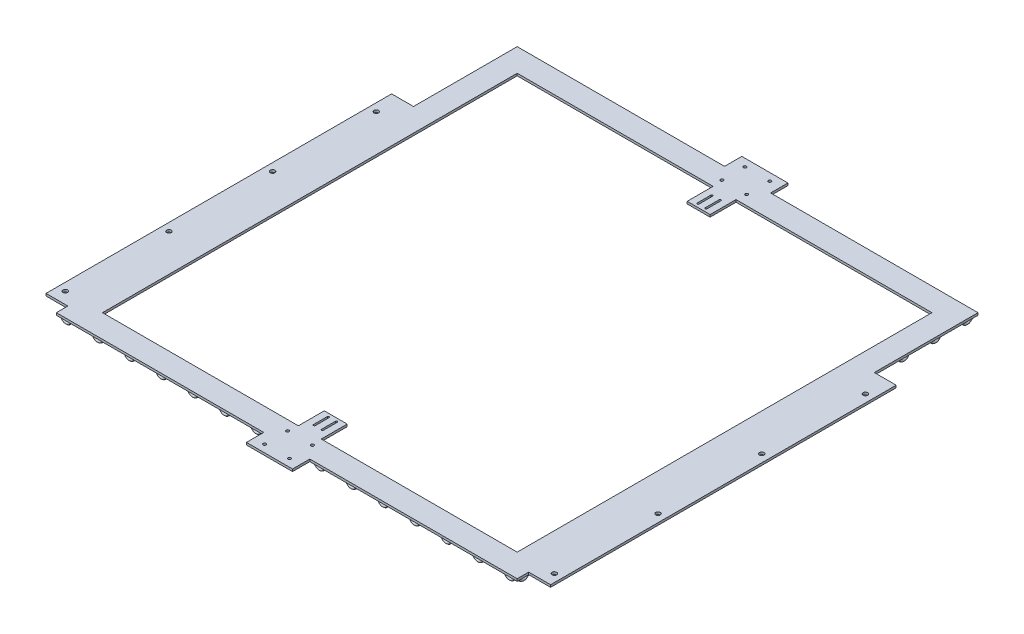
from build123d import *

# Parameters (mm, degrees)
SKETCH_1_R                = 2.5
SKETCH_1_W                = 38
SKETCH_1_H                = 600
EXTRUDE_1_DEPTH           = 4
SKETCH_19_R               = 4
CUT_EXTRUDE_2_DEPTH       = 20
SKETCH_14_R               = 2
SKETCH_18_R               = 2
PATTERN_LINEAR_3_COUNT    = 15
PATTERN_LINEAR_3_PITCH    = 55
MIRROR_1_COPY_1_SKETCH_R  = 2
MIRROR_1_COPY_2_SKETCH_R  = 2
MIRROR_1_COPY_3_SKETCH_R  = 2
MIRROR_1_COPY_4_SKETCH_R  = 2
MIRROR_1_COPY_5_SKETCH_R  = 2
MIRROR_1_COPY_6_SKETCH_R  = 2
MIRROR_1_COPY_7_SKETCH_R  = 2
MIRROR_1_COPY_8_SKETCH_R  = 2
MIRROR_1_COPY_9_SKETCH_R  = 2
MIRROR_1_COPY_10_SKETCH_R = 2
MIRROR_1_COPY_11_SKETCH_R = 2
MIRROR_1_COPY_12_SKETCH_R = 2
MIRROR_1_COPY_13_SKETCH_R = 2
MIRROR_1_COPY_14_SKETCH_R = 2
PATTERN_LINEAR_4_COUNT    = 15
PATTERN_LINEAR_4_PITCH    = 55
MIRROR_2_COPY_1_SKETCH_R  = 2
MIRROR_2_COPY_2_SKETCH_R  = 2
MIRROR_2_COPY_3_SKETCH_R  = 2
MIRROR_2_COPY_4_SKETCH_R  = 2
MIRROR_2_COPY_5_SKETCH_R  = 2
MIRROR_2_COPY_6_SKETCH_R  = 2
MIRROR_2_COPY_7_SKETCH_R  = 2
MIRROR_2_COPY_8_SKETCH_R  = 2
MIRROR_2_COPY_9_SKETCH_R  = 2
MIRROR_2_COPY_10_SKETCH_R = 2
MIRROR_2_COPY_11_SKETCH_R = 2
MIRROR_2_COPY_12_SKETCH_R = 2
MIRROR_2_COPY_13_SKETCH_R = 2


with BuildPart() as part:
    # 草图1 → 凸台-拉伸1 (new body)
    with BuildSketch(Plane(origin=(0, 0, 0), x_dir=(1, 0, 0), z_dir=(0, 1, 0))):
        Polygon((-400, 20), (-400, 0), (-40, 0), (-40, -30), (40, -30), (40, 0), (400, 0), (400, 20), (400, 620), (400, 800), (40, 800), (40, 830), (-40, 830), (-40, 800), (-400, 800), (-400, 620), align=None)
        with Locations((-21.5, -16.998099011)):
            Circle(SKETCH_1_R, mode=Mode.SUBTRACT)
        with Locations((-21.5, 23.001900989)):
            Circle(SKETCH_1_R, mode=Mode.SUBTRACT)
        with BuildLine():
            ThreePointArc((-8.65, 79.001900989), (-7.05, 80.601900989), (-5.45, 79.001900989))
            Line((-5.45, 79.001900989), (-5.45, 55.001900989))
            ThreePointArc((-5.45, 55.001900989), (-7.05, 53.401900989), (-8.65, 55.001900989))
            Line((-8.65, 55.001900989), (-8.65, 79.001900989))
        make_face(mode=Mode.SUBTRACT)
        Polygon((-40, 40), (-360, 40), (-360, 760), (-40, 760), (-19.900430503, 760), (-19.900430503, 715), (19.900430503, 715), (19.900430503, 760), (40, 760), (360, 760), (360, 40), (40, 40), (19.900430503, 40), (19.900430503, 85), (-19.900430503, 85), (-19.900430503, 40), align=None, mode=Mode.SUBTRACT)
        with Locations((21.5, -16.998099011)):
            Circle(SKETCH_1_R, mode=Mode.SUBTRACT)
        with Locations((21.5, 23.001900989)):
            Circle(SKETCH_1_R, mode=Mode.SUBTRACT)
        with BuildLine():
            ThreePointArc((8.65, 55.001900989), (7.05, 53.401900989), (5.45, 55.001900989))
            Line((5.45, 55.001900989), (5.45, 79.001900989))
            ThreePointArc((5.45, 79.001900989), (7.05, 80.601900989), (8.65, 79.001900989))
            Line((8.65, 79.001900989), (8.65, 55.001900989))
        make_face(mode=Mode.SUBTRACT)
        with BuildLine():
            ThreePointArc((-8.65, 744.998099011), (-7.05, 746.598099011), (-5.45, 744.998099011))
            Line((-5.45, 744.998099011), (-5.45, 720.998099011))
            ThreePointArc((-5.45, 720.998099011), (-7.05, 719.398099011), (-8.65, 720.998099011))
            Line((-8.65, 720.998099011), (-8.65, 744.998099011))
        make_face(mode=Mode.SUBTRACT)
        with Locations((-21.5, 776.998099011)):
            Circle(SKETCH_1_R, mode=Mode.SUBTRACT)
        with Locations((-21.5, 816.998099011)):
            Circle(SKETCH_1_R, mode=Mode.SUBTRACT)
        with BuildLine():
            ThreePointArc((8.65, 720.998099011), (7.05, 719.398099011), (5.45, 720.998099011))
            Line((5.45, 720.998099011), (5.45, 744.998099011))
            ThreePointArc((5.45, 744.998099011), (7.05, 746.598099011), (8.65, 744.998099011))
            Line((8.65, 744.998099011), (8.65, 720.998099011))
        make_face(mode=Mode.SUBTRACT)
        with Locations((21.5, 776.998099011)):
            Circle(SKETCH_1_R, mode=Mode.SUBTRACT)
        with Locations((21.5, 816.998099011)):
            Circle(SKETCH_1_R, mode=Mode.SUBTRACT)
        with Locations((419, 320)):
            Rectangle(SKETCH_1_W, SKETCH_1_H)
        with Locations((-419, 320)):
            Rectangle(SKETCH_1_W, SKETCH_1_H)
    extrude(amount=EXTRUDE_1_DEPTH)

    # 草图19 → 切除-拉伸2 (cut, symmetric)
    with BuildSketch(Plane(origin=(0, 0, 0), x_dir=(1, 0, 0), z_dir=(0, 1, 0))):
        with Locations((-424.498179324, 220)):
            Circle(SKETCH_19_R)
        with Locations((-424.498179324, 400)):
            Circle(SKETCH_19_R)
        with Locations((-424.498179324, 580)):
            Circle(SKETCH_19_R)
        with Locations((-424.498179324, 40)):
            Circle(SKETCH_19_R)
        with Locations((424.498179324, 40)):
            Circle(SKETCH_19_R)
        with Locations((424.498179324, 580)):
            Circle(SKETCH_19_R)
        with Locations((424.498179324, 400)):
            Circle(SKETCH_19_R)
        with Locations((424.498179324, 220)):
            Circle(SKETCH_19_R)
    extrude(amount=CUT_EXTRUDE_2_DEPTH, both=True, mode=Mode.SUBTRACT)

    # 扫描1: sweep along a path in 草图12
    with BuildLine(Plane.XY.offset(-6)) as sweep_1_path:
        ThreePointArc((-396, 0), (-388, -8), (-380, 0))
    # 草图14 → 扫描1 (sweep)
    with BuildSketch(Plane(origin=(0, 0, 0), x_dir=(1, 0, 0), z_dir=(0, 1, 0))):
        with Locations((-396, 6)):
            Circle(SKETCH_14_R)
    sweep_1 = sweep(path=sweep_1_path.line)

    # 扫描3: sweep along a path in 草图17
    with BuildLine(Plane.ZY.offset(394)) as sweep_3_path:
        ThreePointArc((-794.32, 0), (-786.32, -8), (-778.32, 0))
    # 草图18 → 扫描3 (sweep)
    with BuildSketch(Plane(origin=(0, 0, 0), x_dir=(1, 0, 0), z_dir=(0, 1, 0))):
        with Locations((-394, 794.32)):
            Circle(SKETCH_18_R)
    sweep_3 = sweep(path=sweep_3_path.line)

    # 阵列(线性)3: 扫描3 ×15
    with Locations(*[(0, 0, i * PATTERN_LINEAR_3_PITCH) for i in range(1, PATTERN_LINEAR_3_COUNT)]):
        add(sweep_3)

    # 镜向1: 扫描3 across plane
    add(sweep_3.mirror(Plane(origin=(0, 0, 0), x_dir=(0, 0, 1), z_dir=(1, 0, 0))))

    # 镜向1 copy 1: sweep along a path in 镜向1 copy 1 path
    with BuildLine(Plane(origin=(394, 0, 55), x_dir=(0, 0, 1), z_dir=(1, 0, 0))) as mirror_1_copy_1_path:
        ThreePointArc((-794.32, 0), (-786.32, 8), (-778.32, 0))
    # 镜向1 copy 1 sketch → 镜向1 copy 1 (sweep)
    with BuildSketch(Plane(origin=(0, 0, 55), x_dir=(-1, 0, 0), z_dir=(0, 1, 0))):
        with Locations((-394, -794.32)):
            Circle(MIRROR_1_COPY_1_SKETCH_R)
    sweep(path=mirror_1_copy_1_path.line)

    # 镜向1 copy 2: sweep along a path in 镜向1 copy 2 path
    with BuildLine(Plane(origin=(394, 0, 110), x_dir=(0, 0, 1), z_dir=(1, 0, 0))) as mirror_1_copy_2_path:
        ThreePointArc((-794.32, 0), (-786.32, 8), (-778.32, 0))
    # 镜向1 copy 2 sketch → 镜向1 copy 2 (sweep)
    with BuildSketch(Plane(origin=(0, 0, 110), x_dir=(-1, 0, 0), z_dir=(0, 1, 0))):
        with Locations((-394, -794.32)):
            Circle(MIRROR_1_COPY_2_SKETCH_R)
    sweep(path=mirror_1_copy_2_path.line)

    # 镜向1 copy 3: sweep along a path in 镜向1 copy 3 path
    with BuildLine(Plane(origin=(394, 0, 165), x_dir=(0, 0, 1), z_dir=(1, 0, 0))) as mirror_1_copy_3_path:
        ThreePointArc((-794.32, 0), (-786.32, 8), (-778.32, 0))
    # 镜向1 copy 3 sketch → 镜向1 copy 3 (sweep)
    with BuildSketch(Plane(origin=(0, 0, 165), x_dir=(-1, 0, 0), z_dir=(0, 1, 0))):
        with Locations((-394, -794.32)):
            Circle(MIRROR_1_COPY_3_SKETCH_R)
    sweep(path=mirror_1_copy_3_path.line)

    # 镜向1 copy 4: sweep along a path in 镜向1 copy 4 path
    with BuildLine(Plane(origin=(394, 0, 220), x_dir=(0, 0, 1), z_dir=(1, 0, 0))) as mirror_1_copy_4_path:
        ThreePointArc((-794.32, 0), (-786.32, 8), (-778.32, 0))
    # 镜向1 copy 4 sketch → 镜向1 copy 4 (sweep)
    with BuildSketch(Plane(origin=(0, 0, 220), x_dir=(-1, 0, 0), z_dir=(0, 1, 0))):
        with Locations((-394, -794.32)):
            Circle(MIRROR_1_COPY_4_SKETCH_R)
    sweep(path=mirror_1_copy_4_path.line)

    # 镜向1 copy 5: sweep along a path in 镜向1 copy 5 path
    with BuildLine(Plane(origin=(394, 0, 275), x_dir=(0, 0, 1), z_dir=(1, 0, 0))) as mirror_1_copy_5_path:
        ThreePointArc((-794.32, 0), (-786.32, 8), (-778.32, 0))
    # 镜向1 copy 5 sketch → 镜向1 copy 5 (sweep)
    with BuildSketch(Plane(origin=(0, 0, 275), x_dir=(-1, 0, 0), z_dir=(0, 1, 0))):
        with Locations((-394, -794.32)):
            Circle(MIRROR_1_COPY_5_SKETCH_R)
    sweep(path=mirror_1_copy_5_path.line)

    # 镜向1 copy 6: sweep along a path in 镜向1 copy 6 path
    with BuildLine(Plane(origin=(394, 0, 330), x_dir=(0, 0, 1), z_dir=(1, 0, 0))) as mirror_1_copy_6_path:
        ThreePointArc((-794.32, 0), (-786.32, 8), (-778.32, 0))
    # 镜向1 copy 6 sketch → 镜向1 copy 6 (sweep)
    with BuildSketch(Plane(origin=(0, 0, 330), x_dir=(-1, 0, 0), z_dir=(0, 1, 0))):
        with Locations((-394, -794.32)):
            Circle(MIRROR_1_COPY_6_SKETCH_R)
    sweep(path=mirror_1_copy_6_path.line)

    # 镜向1 copy 7: sweep along a path in 镜向1 copy 7 path
    with BuildLine(Plane(origin=(394, 0, 385), x_dir=(0, 0, 1), z_dir=(1, 0, 0))) as mirror_1_copy_7_path:
        ThreePointArc((-794.32, 0), (-786.32, 8), (-778.32, 0))
    # 镜向1 copy 7 sketch → 镜向1 copy 7 (sweep)
    with BuildSketch(Plane(origin=(0, 0, 385), x_dir=(-1, 0, 0), z_dir=(0, 1, 0))):
        with Locations((-394, -794.32)):
            Circle(MIRROR_1_COPY_7_SKETCH_R)
    sweep(path=mirror_1_copy_7_path.line)

    # 镜向1 copy 8: sweep along a path in 镜向1 copy 8 path
    with BuildLine(Plane(origin=(394, 0, 440), x_dir=(0, 0, 1), z_dir=(1, 0, 0))) as mirror_1_copy_8_path:
        ThreePointArc((-794.32, 0), (-786.32, 8), (-778.32, 0))
    # 镜向1 copy 8 sketch → 镜向1 copy 8 (sweep)
    with BuildSketch(Plane(origin=(0, 0, 440), x_dir=(-1, 0, 0), z_dir=(0, 1, 0))):
        with Locations((-394, -794.32)):
            Circle(MIRROR_1_COPY_8_SKETCH_R)
    sweep(path=mirror_1_copy_8_path.line)

    # 镜向1 copy 9: sweep along a path in 镜向1 copy 9 path
    with BuildLine(Plane(origin=(394, 0, 495), x_dir=(0, 0, 1), z_dir=(1, 0, 0))) as mirror_1_copy_9_path:
        ThreePointArc((-794.32, 0), (-786.32, 8), (-778.32, 0))
    # 镜向1 copy 9 sketch → 镜向1 copy 9 (sweep)
    with BuildSketch(Plane(origin=(0, 0, 495), x_dir=(-1, 0, 0), z_dir=(0, 1, 0))):
        with Locations((-394, -794.32)):
            Circle(MIRROR_1_COPY_9_SKETCH_R)
    sweep(path=mirror_1_copy_9_path.line)

    # 镜向1 copy 10: sweep along a path in 镜向1 copy 10 path
    with BuildLine(Plane(origin=(394, 0, 550), x_dir=(0, 0, 1), z_dir=(1, 0, 0))) as mirror_1_copy_10_path:
        ThreePointArc((-794.32, 0), (-786.32, 8), (-778.32, 0))
    # 镜向1 copy 10 sketch → 镜向1 copy 10 (sweep)
    with BuildSketch(Plane(origin=(0, 0, 550), x_dir=(-1, 0, 0), z_dir=(0, 1, 0))):
        with Locations((-394, -794.32)):
            Circle(MIRROR_1_COPY_10_SKETCH_R)
    sweep(path=mirror_1_copy_10_path.line)

    # 镜向1 copy 11: sweep along a path in 镜向1 copy 11 path
    with BuildLine(Plane(origin=(394, 0, 605), x_dir=(0, 0, 1), z_dir=(1, 0, 0))) as mirror_1_copy_11_path:
        ThreePointArc((-794.32, 0), (-786.32, 8), (-778.32, 0))
    # 镜向1 copy 11 sketch → 镜向1 copy 11 (sweep)
    with BuildSketch(Plane(origin=(0, 0, 605), x_dir=(-1, 0, 0), z_dir=(0, 1, 0))):
        with Locations((-394, -794.32)):
            Circle(MIRROR_1_COPY_11_SKETCH_R)
    sweep(path=mirror_1_copy_11_path.line)

    # 镜向1 copy 12: sweep along a path in 镜向1 copy 12 path
    with BuildLine(Plane(origin=(394, 0, 660), x_dir=(0, 0, 1), z_dir=(1, 0, 0))) as mirror_1_copy_12_path:
        ThreePointArc((-794.32, 0), (-786.32, 8), (-778.32, 0))
    # 镜向1 copy 12 sketch → 镜向1 copy 12 (sweep)
    with BuildSketch(Plane(origin=(0, 0, 660), x_dir=(-1, 0, 0), z_dir=(0, 1, 0))):
        with Locations((-394, -794.32)):
            Circle(MIRROR_1_COPY_12_SKETCH_R)
    sweep(path=mirror_1_copy_12_path.line)

    # 镜向1 copy 13: sweep along a path in 镜向1 copy 13 path
    with BuildLine(Plane(origin=(394, 0, 715), x_dir=(0, 0, 1), z_dir=(1, 0, 0))) as mirror_1_copy_13_path:
        ThreePointArc((-794.32, 0), (-786.32, 8), (-778.32, 0))
    # 镜向1 copy 13 sketch → 镜向1 copy 13 (sweep)
    with BuildSketch(Plane(origin=(0, 0, 715), x_dir=(-1, 0, 0), z_dir=(0, 1, 0))):
        with Locations((-394, -794.32)):
            Circle(MIRROR_1_COPY_13_SKETCH_R)
    sweep(path=mirror_1_copy_13_path.line)

    # 镜向1 copy 14: sweep along a path in 镜向1 copy 14 path
    with BuildLine(Plane(origin=(394, 0, 770), x_dir=(0, 0, 1), z_dir=(1, 0, 0))) as mirror_1_copy_14_path:
        ThreePointArc((-794.32, 0), (-786.32, 8), (-778.32, 0))
    # 镜向1 copy 14 sketch → 镜向1 copy 14 (sweep)
    with BuildSketch(Plane(origin=(0, 0, 770), x_dir=(-1, 0, 0), z_dir=(0, 1, 0))):
        with Locations((-394, -794.32)):
            Circle(MIRROR_1_COPY_14_SKETCH_R)
    sweep(path=mirror_1_copy_14_path.line)

    # 阵列(线性)4: 扫描1 ×15, 1 skipped
    with Locations(*[(i * PATTERN_LINEAR_4_PITCH, 0, 0) for i in range(1, PATTERN_LINEAR_4_COUNT) if i not in (7,)]):
        add(sweep_1)

    # 镜向2: 扫描1 across plane
    add(sweep_1.mirror(Plane.XY.offset(-400)))

    # 镜向2 copy 1: sweep along a path in 镜向2 copy 1 path
    with BuildLine(Plane(origin=(55, 0, -794), x_dir=(1, 0, 0), z_dir=(0, 0, -1))) as mirror_2_copy_1_path:
        ThreePointArc((-396, 0), (-388, 8), (-380, 0))
    # 镜向2 copy 1 sketch → 镜向2 copy 1 (sweep)
    with BuildSketch(Plane(origin=(55, 0, -800), x_dir=(1, 0, 0), z_dir=(0, 1, 0))):
        with Locations((-396, -6)):
            Circle(MIRROR_2_COPY_1_SKETCH_R)
    sweep(path=mirror_2_copy_1_path.line)

    # 镜向2 copy 2: sweep along a path in 镜向2 copy 2 path
    with BuildLine(Plane(origin=(110, 0, -794), x_dir=(1, 0, 0), z_dir=(0, 0, -1))) as mirror_2_copy_2_path:
        ThreePointArc((-396, 0), (-388, 8), (-380, 0))
    # 镜向2 copy 2 sketch → 镜向2 copy 2 (sweep)
    with BuildSketch(Plane(origin=(110, 0, -800), x_dir=(1, 0, 0), z_dir=(0, 1, 0))):
        with Locations((-396, -6)):
            Circle(MIRROR_2_COPY_2_SKETCH_R)
    sweep(path=mirror_2_copy_2_path.line)

    # 镜向2 copy 3: sweep along a path in 镜向2 copy 3 path
    with BuildLine(Plane(origin=(165, 0, -794), x_dir=(1, 0, 0), z_dir=(0, 0, -1))) as mirror_2_copy_3_path:
        ThreePointArc((-396, 0), (-388, 8), (-380, 0))
    # 镜向2 copy 3 sketch → 镜向2 copy 3 (sweep)
    with BuildSketch(Plane(origin=(165, 0, -800), x_dir=(1, 0, 0), z_dir=(0, 1, 0))):
        with Locations((-396, -6)):
            Circle(MIRROR_2_COPY_3_SKETCH_R)
    sweep(path=mirror_2_copy_3_path.line)

    # 镜向2 copy 4: sweep along a path in 镜向2 copy 4 path
    with BuildLine(Plane(origin=(220, 0, -794), x_dir=(1, 0, 0), z_dir=(0, 0, -1))) as mirror_2_copy_4_path:
        ThreePointArc((-396, 0), (-388, 8), (-380, 0))
    # 镜向2 copy 4 sketch → 镜向2 copy 4 (sweep)
    with BuildSketch(Plane(origin=(220, 0, -800), x_dir=(1, 0, 0), z_dir=(0, 1, 0))):
        with Locations((-396, -6)):
            Circle(MIRROR_2_COPY_4_SKETCH_R)
    sweep(path=mirror_2_copy_4_path.line)

    # 镜向2 copy 5: sweep along a path in 镜向2 copy 5 path
    with BuildLine(Plane(origin=(275, 0, -794), x_dir=(1, 0, 0), z_dir=(0, 0, -1))) as mirror_2_copy_5_path:
        ThreePointArc((-396, 0), (-388, 8), (-380, 0))
    # 镜向2 copy 5 sketch → 镜向2 copy 5 (sweep)
    with BuildSketch(Plane(origin=(275, 0, -800), x_dir=(1, 0, 0), z_dir=(0, 1, 0))):
        with Locations((-396, -6)):
            Circle(MIRROR_2_COPY_5_SKETCH_R)
    sweep(path=mirror_2_copy_5_path.line)

    # 镜向2 copy 6: sweep along a path in 镜向2 copy 6 path
    with BuildLine(Plane(origin=(330, 0, -794), x_dir=(1, 0, 0), z_dir=(0, 0, -1))) as mirror_2_copy_6_path:
        ThreePointArc((-396, 0), (-388, 8), (-380, 0))
    # 镜向2 copy 6 sketch → 镜向2 copy 6 (sweep)
    with BuildSketch(Plane(origin=(330, 0, -800), x_dir=(1, 0, 0), z_dir=(0, 1, 0))):
        with Locations((-396, -6)):
            Circle(MIRROR_2_COPY_6_SKETCH_R)
    sweep(path=mirror_2_copy_6_path.line)

    # 镜向2 copy 7: sweep along a path in 镜向2 copy 7 path
    with BuildLine(Plane(origin=(440, 0, -794), x_dir=(1, 0, 0), z_dir=(0, 0, -1))) as mirror_2_copy_7_path:
        ThreePointArc((-396, 0), (-388, 8), (-380, 0))
    # 镜向2 copy 7 sketch → 镜向2 copy 7 (sweep)
    with BuildSketch(Plane(origin=(440, 0, -800), x_dir=(1, 0, 0), z_dir=(0, 1, 0))):
        with Locations((-396, -6)):
            Circle(MIRROR_2_COPY_7_SKETCH_R)
    sweep(path=mirror_2_copy_7_path.line)

    # 镜向2 copy 8: sweep along a path in 镜向2 copy 8 path
    with BuildLine(Plane(origin=(495, 0, -794), x_dir=(1, 0, 0), z_dir=(0, 0, -1))) as mirror_2_copy_8_path:
        ThreePointArc((-396, 0), (-388, 8), (-380, 0))
    # 镜向2 copy 8 sketch → 镜向2 copy 8 (sweep)
    with BuildSketch(Plane(origin=(495, 0, -800), x_dir=(1, 0, 0), z_dir=(0, 1, 0))):
        with Locations((-396, -6)):
            Circle(MIRROR_2_COPY_8_SKETCH_R)
    sweep(path=mirror_2_copy_8_path.line)

    # 镜向2 copy 9: sweep along a path in 镜向2 copy 9 path
    with BuildLine(Plane(origin=(550, 0, -794), x_dir=(1, 0, 0), z_dir=(0, 0, -1))) as mirror_2_copy_9_path:
        ThreePointArc((-396, 0), (-388, 8), (-380, 0))
    # 镜向2 copy 9 sketch → 镜向2 copy 9 (sweep)
    with BuildSketch(Plane(origin=(550, 0, -800), x_dir=(1, 0, 0), z_dir=(0, 1, 0))):
        with Locations((-396, -6)):
            Circle(MIRROR_2_COPY_9_SKETCH_R)
    sweep(path=mirror_2_copy_9_path.line)

    # 镜向2 copy 10: sweep along a path in 镜向2 copy 10 path
    with BuildLine(Plane(origin=(605, 0, -794), x_dir=(1, 0, 0), z_dir=(0, 0, -1))) as mirror_2_copy_10_path:
        ThreePointArc((-396, 0), (-388, 8), (-380, 0))
    # 镜向2 copy 10 sketch → 镜向2 copy 10 (sweep)
    with BuildSketch(Plane(origin=(605, 0, -800), x_dir=(1, 0, 0), z_dir=(0, 1, 0))):
        with Locations((-396, -6)):
            Circle(MIRROR_2_COPY_10_SKETCH_R)
    sweep(path=mirror_2_copy_10_path.line)

    # 镜向2 copy 11: sweep along a path in 镜向2 copy 11 path
    with BuildLine(Plane(origin=(660, 0, -794), x_dir=(1, 0, 0), z_dir=(0, 0, -1))) as mirror_2_copy_11_path:
        ThreePointArc((-396, 0), (-388, 8), (-380, 0))
    # 镜向2 copy 11 sketch → 镜向2 copy 11 (sweep)
    with BuildSketch(Plane(origin=(660, 0, -800), x_dir=(1, 0, 0), z_dir=(0, 1, 0))):
        with Locations((-396, -6)):
            Circle(MIRROR_2_COPY_11_SKETCH_R)
    sweep(path=mirror_2_copy_11_path.line)

    # 镜向2 copy 12: sweep along a path in 镜向2 copy 12 path
    with BuildLine(Plane(origin=(715, 0, -794), x_dir=(1, 0, 0), z_dir=(0, 0, -1))) as mirror_2_copy_12_path:
        ThreePointArc((-396, 0), (-388, 8), (-380, 0))
    # 镜向2 copy 12 sketch → 镜向2 copy 12 (sweep)
    with BuildSketch(Plane(origin=(715, 0, -800), x_dir=(1, 0, 0), z_dir=(0, 1, 0))):
        with Locations((-396, -6)):
            Circle(MIRROR_2_COPY_12_SKETCH_R)
    sweep(path=mirror_2_copy_12_path.line)

    # 镜向2 copy 13: sweep along a path in 镜向2 copy 13 path
    with BuildLine(Plane(origin=(770, 0, -794), x_dir=(1, 0, 0), z_dir=(0, 0, -1))) as mirror_2_copy_13_path:
        ThreePointArc((-396, 0), (-388, 8), (-380, 0))
    # 镜向2 copy 13 sketch → 镜向2 copy 13 (sweep)
    with BuildSketch(Plane(origin=(770, 0, -800), x_dir=(1, 0, 0), z_dir=(0, 1, 0))):
        with Locations((-396, -6)):
            Circle(MIRROR_2_COPY_13_SKETCH_R)
    sweep(path=mirror_2_copy_13_path.line)


solid = part.part
